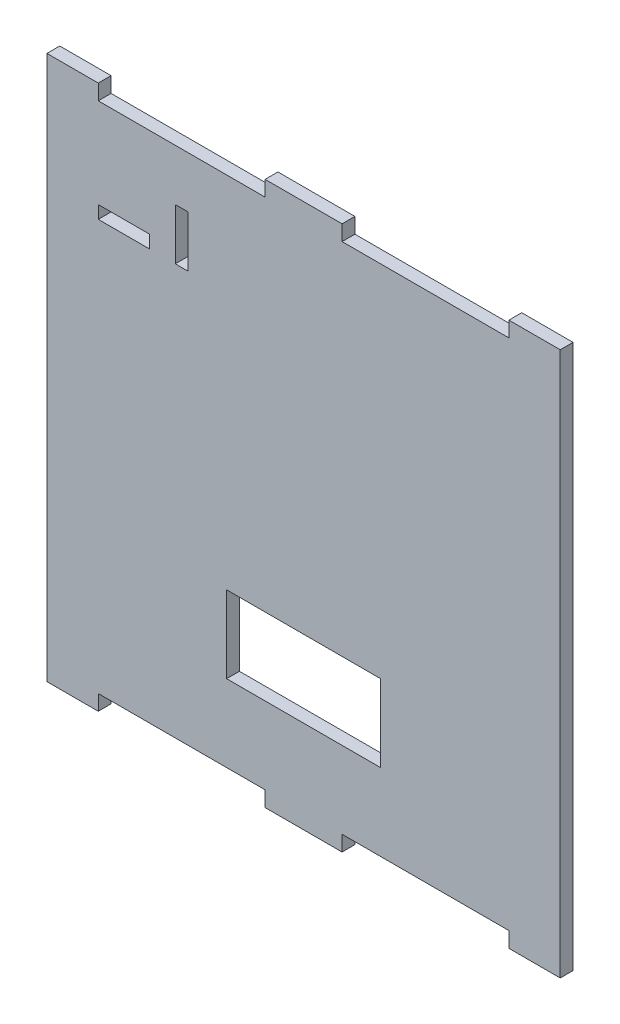
from build123d import *

# Parameters (mm, degrees)
ESQUISSE1_W        = 60
ESQUISSE1_H        = 30
ESQUISSE1_W_2      = 20
ESQUISSE1_H_2      = 5
ESQUISSE1_W_3      = 5
ESQUISSE1_H_3      = 20
BOSS_EXTRU_1_DEPTH = 5


with BuildPart() as part:
    # Esquisse1 → Boss.-Extru.1 (new body)
    with BuildSketch(Plane.XY):
        Polygon((0, 0), (0, 212), (20, 212), (20, 206), (85, 206), (85, 212), (115, 212), (115, 206), (180, 206), (180, 212), (200, 212), (200, 0), (180, 0), (180, 6), (115, 6), (115, 0), (85, 0), (85, 6), (20, 6), (20, 0), align=None)
        with Locations((100, 51)):
            Rectangle(ESQUISSE1_W, ESQUISSE1_H, mode=Mode.SUBTRACT)
        with Locations((30, 168.5)):
            Rectangle(ESQUISSE1_W_2, ESQUISSE1_H_2, mode=Mode.SUBTRACT)
        with Locations((52.5, 176)):
            Rectangle(ESQUISSE1_W_3, ESQUISSE1_H_3, mode=Mode.SUBTRACT)
    extrude(amount=BOSS_EXTRU_1_DEPTH)


solid = part.part
